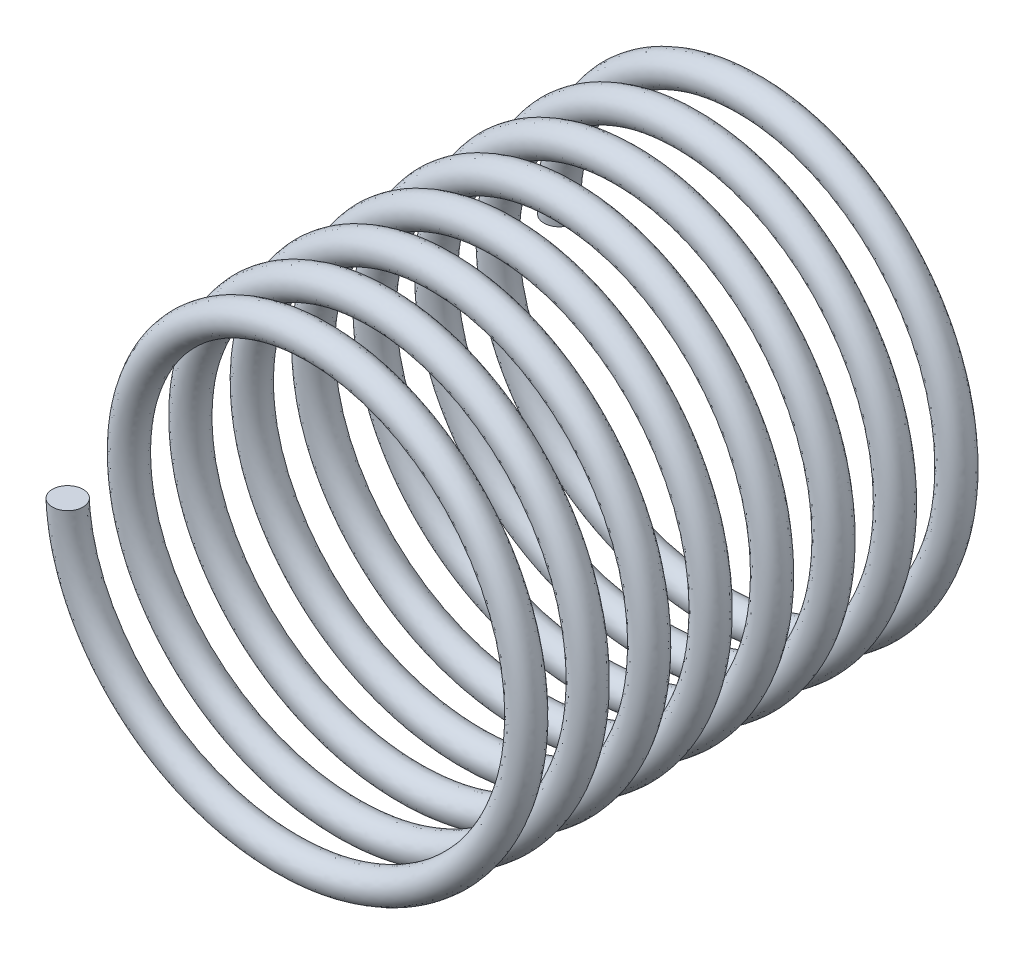
from build123d import *

# Parameters (mm, degrees)
SWEEP1_PITCH       = 1
SWEEP1_HEIGHT      = 8
SWEEP1_RADIUS      = 3
SWEEP1_START_ANGLE = -180
SKETCH2_R          = 0.25


with BuildPart() as part:
    # Sweep1: sweep along a helix
    with BuildLine() as sweep1_path:
        add(Helix(SWEEP1_PITCH, SWEEP1_HEIGHT, SWEEP1_RADIUS, center=(0, 0, 0), direction=(0, 0, 1), lefthand=True, mode=Mode.PRIVATE).rotate(Axis((0, 0, 0), (0, 0, 1)), SWEEP1_START_ANGLE))
    # Sketch2 → Sweep1 (sweep)
    with BuildSketch(Plane(origin=(0, 0, 0), x_dir=(1, 0, 0), z_dir=(0, 1, 0))):
        with Locations((-3.479271877, -7.995460357)):
            Circle(SKETCH2_R)
    sweep(path=sweep1_path.line, is_frenet=True)


solid = part.part
